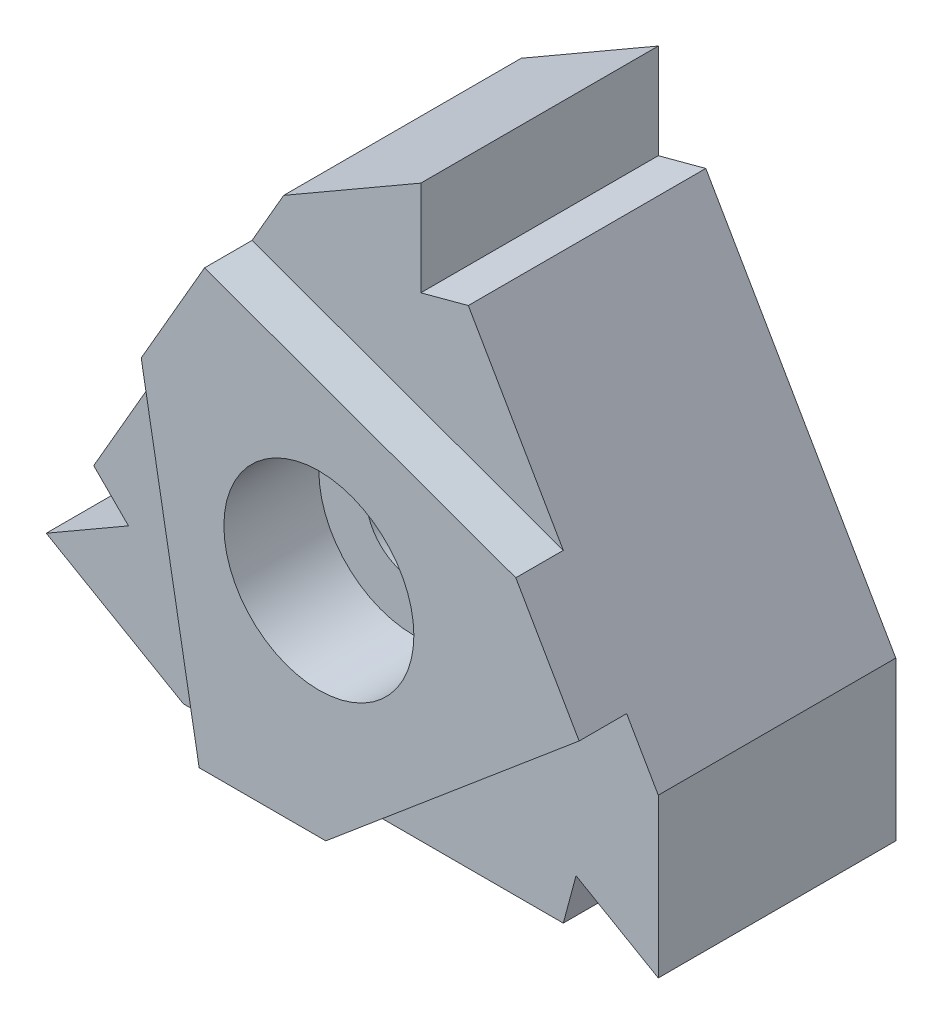
from build123d import *

# Parameters (mm, degrees)
EXTRUDE_1_DEPTH           = 9
CUT_EXTRUDE_5_DEPTH       = 1.5
HOLE_WIZARD_1_D           = 3
HOLE_WIZARD_1_CBORE_D     = 6
HOLE_WIZARD_1_CBORE_DEPTH = 3


with BuildPart() as part:
    # 草图1 → 凸台-拉伸1 (new body)
    with BuildSketch(Plane.XY):
        Polygon((-37.234772054, 15.490381057), (-43.234772054, 5.098076211), (-42.136695843, 4), (-44.734772054, 2.5), (-40.404645035, 0), (-28.404645035, 0), (-28.002721246, 1.5), (-25.404645035, 0), (-25.404645035, 5), (-31.404645035, 15.392304845), (-32.904645035, 14.990381057), (-32.904645035, 17.990381057), align=None)
    extrude(amount=EXTRUDE_1_DEPTH)

    # 草图2 → 切除-拉伸5 (cut)
    with BuildSketch(Plane.XY.offset(9)):
        Polygon((-38.404645035, 0), (-40.234772054, 10.294228634), (-43.234772054, 5.098076211), (-42.136695843, 4), (-44.734772054, 2.5), (-40.404645035, 0), align=None)
        Polygon((-38.234772054, 13.758330249), (-28.404645035, 10.196152423), (-31.404645035, 15.392304845), (-32.904645035, 14.990381057), (-32.904645035, 17.990381057), (-37.234772054, 15.490381057), align=None)
        Polygon((-26.404645035, 6.732050808), (-34.404645035, 0), (-28.404645035, 0), (-28.002721246, 1.5), (-25.404645035, 0), (-25.404645035, 5), align=None)
    extrude(amount=-CUT_EXTRUDE_5_DEPTH, mode=Mode.SUBTRACT)

    # 孔1 (through all)
    with Locations(Plane.XY.offset(9)):
        with Locations((-34.624141854, 7.012125204)):
            CounterBoreHole(HOLE_WIZARD_1_D / 2, HOLE_WIZARD_1_CBORE_D / 2, HOLE_WIZARD_1_CBORE_DEPTH)


solid = part.part
